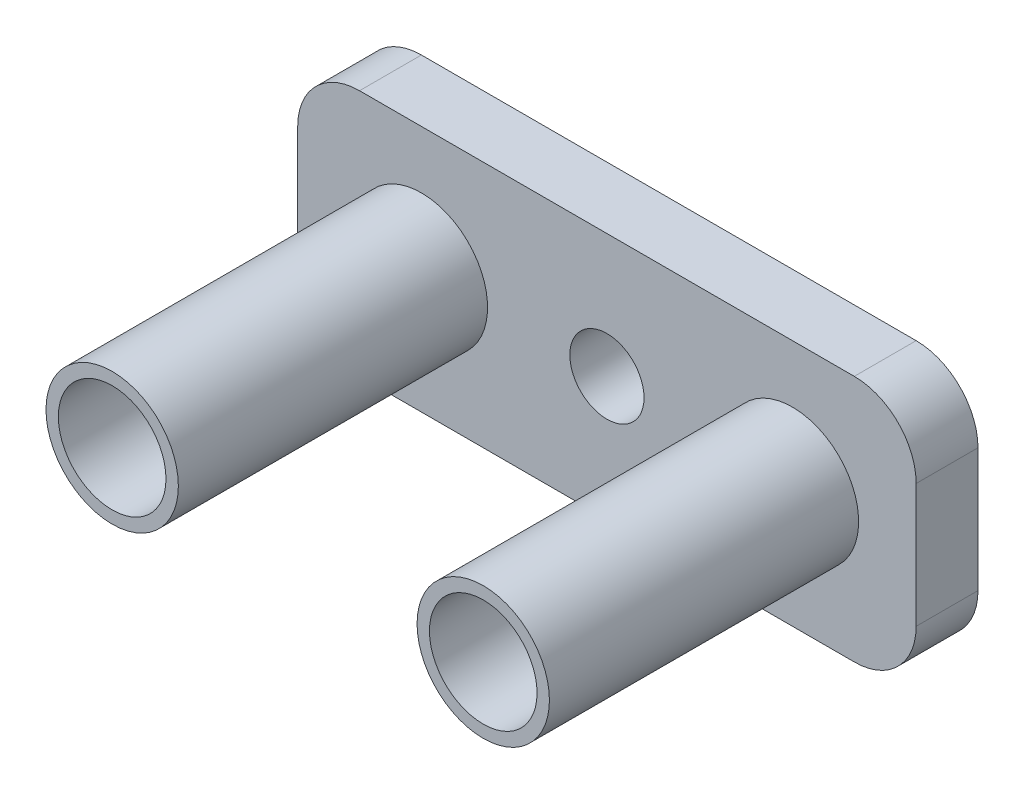
from build123d import *

# Parameters (mm, degrees)
SKETCH1_R           = 4.85
SKETCH1_R_2         = 3
BOSS_EXTRUDE5_DEPTH = 5
SKETCH1_7_R         = 4.85
BOSS_EXTRUDE6_DEPTH = 5
SKETCH1_8_R         = 5.35
SKETCH1_8_R_2       = 4.35
EXTRUDE_THIN1_DEPTH = 30


with BuildPart() as part:
    # Sketch1 → Boss-Extrude5 (new body)
    with BuildSketch(Plane.XY):
        with BuildLine():
            Line((-14.029850746, 6.623134328), (25.970149254, 6.623134328))
            ThreePointArc((25.970149254, 6.623134328), (29.50568316, 5.158668234), (30.970149254, 1.623134328))
            Line((30.970149254, 1.623134328), (30.970149254, -8.376865672))
            ThreePointArc((30.970149254, -8.376865672), (29.50568316, -11.912399578), (25.970149254, -13.376865672))
            Line((25.970149254, -13.376865672), (-14.029850746, -13.376865672))
            ThreePointArc((-14.029850746, -13.376865672), (-17.565384652, -11.912399578), (-19.029850746, -8.376865672))
            Line((-19.029850746, -8.376865672), (-19.029850746, 1.623134328))
            ThreePointArc((-19.029850746, 1.623134328), (-17.565384652, 5.158668234), (-14.029850746, 6.623134328))
        make_face()
        with Locations((-9.029850746, -3.376865672)):
            Circle(SKETCH1_R, mode=Mode.SUBTRACT)
        with Locations((20.970149254, -3.376865672)):
            Circle(SKETCH1_R, mode=Mode.SUBTRACT)
        with Locations((5.970149254, -3.376865672)):
            Circle(SKETCH1_R_2, mode=Mode.SUBTRACT)
    extrude(amount=BOSS_EXTRUDE5_DEPTH)

    # Sketch1_7 → Boss-Extrude6 (add)
    with BuildSketch(Plane.XY):
        with Locations((-9.029850746, -3.376865672)):
            Circle(SKETCH1_7_R)
        with Locations((20.970149254, -3.376865672)):
            Circle(SKETCH1_7_R)
    extrude(amount=BOSS_EXTRUDE6_DEPTH)

    # Sketch1_8 → Extrude-Thin1 (add)
    with BuildSketch(Plane.XY):
        with Locations((-9.029850746, -3.376865672)):
            Circle(SKETCH1_8_R)
        with Locations((-9.029850746, -3.376865672)):
            Circle(SKETCH1_8_R_2, mode=Mode.SUBTRACT)
        with Locations((20.970149254, -3.376865672)):
            Circle(SKETCH1_8_R)
        with Locations((20.970149254, -3.376865672)):
            Circle(SKETCH1_8_R_2, mode=Mode.SUBTRACT)
    extrude(amount=EXTRUDE_THIN1_DEPTH)


solid = part.part
